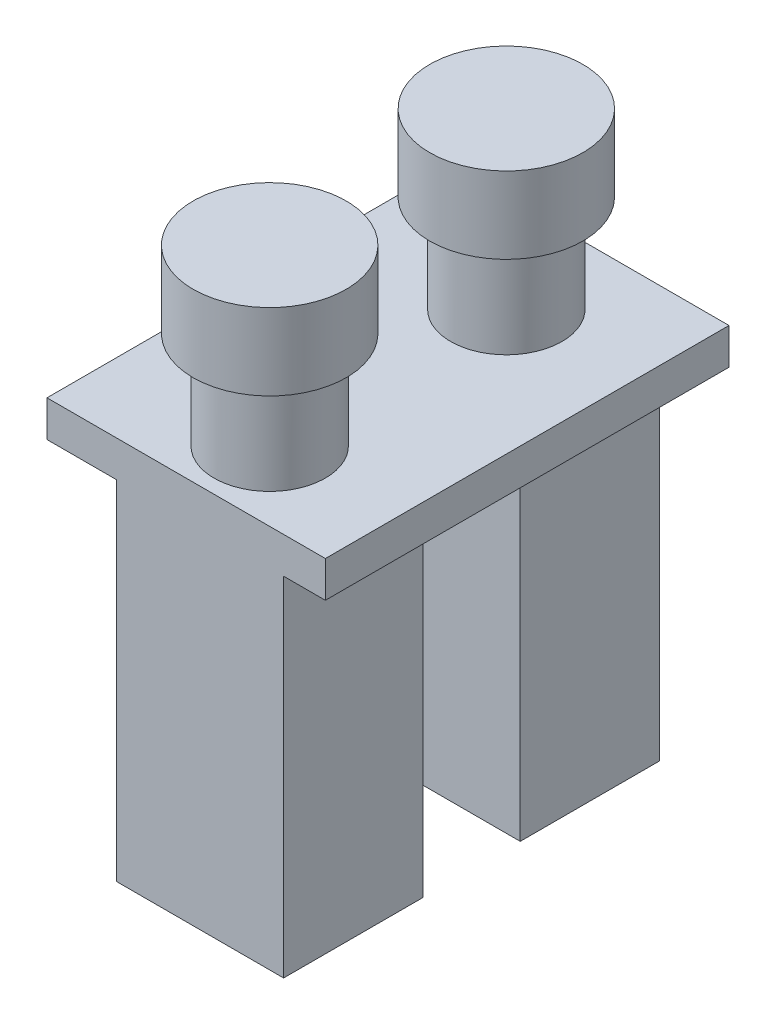
from build123d import *

# Parameters (mm, degrees)
SKICA1_W                = 20
SKICA1_H                = 29
P_IDAT_VYSUNUT_M1_DEPTH = 2.6
SKICA2_R                = 4
P_IDAT_VYSUNUT_M2_DEPTH = 7
SKICA3_R                = 5.5
P_IDAT_VYSUNUT_M3_DEPTH = 5.5
SKICA5_W                = 12
SKICA5_H                = 10
P_IDAT_VYSUNUT_M4_DEPTH = 25


with BuildPart() as part:
    # Skica1 → Přidat vysunutím1 (new body)
    with BuildSketch(Plane(origin=(0, 0, 0), x_dir=(1, 0, 0), z_dir=(0, 1, 0))):
        with Locations((10, 14.5)):
            Rectangle(SKICA1_W, SKICA1_H)
    extrude(amount=P_IDAT_VYSUNUT_M1_DEPTH)

    # Skica2 → Přidat vysunutím2 (add)
    with BuildSketch(Plane(origin=(0, 2.6, 0), x_dir=(1, 0, 0), z_dir=(0, 1, 0))):
        with Locations((11, 5)):
            Circle(SKICA2_R)
        with Locations((11, 22)):
            Circle(SKICA2_R)
    extrude(amount=P_IDAT_VYSUNUT_M2_DEPTH)

    # Skica3 → Přidat vysunutím3 (add)
    with BuildSketch(Plane(origin=(0, 9.6, 0), x_dir=(1, 0, 0), z_dir=(0, 1, 0))):
        with Locations((11, 22)):
            Circle(SKICA3_R)
        with Locations((11, 5)):
            Circle(SKICA3_R)
    extrude(amount=P_IDAT_VYSUNUT_M3_DEPTH)

    # Skica5 → Přidat vysunutím4 (add)
    with BuildSketch(Plane.XZ):
        with Locations((11, -22)):
            Rectangle(SKICA5_W, SKICA5_H)
        with Locations((11, -5)):
            Rectangle(SKICA5_W, SKICA5_H)
    extrude(amount=P_IDAT_VYSUNUT_M4_DEPTH)


solid = part.part
